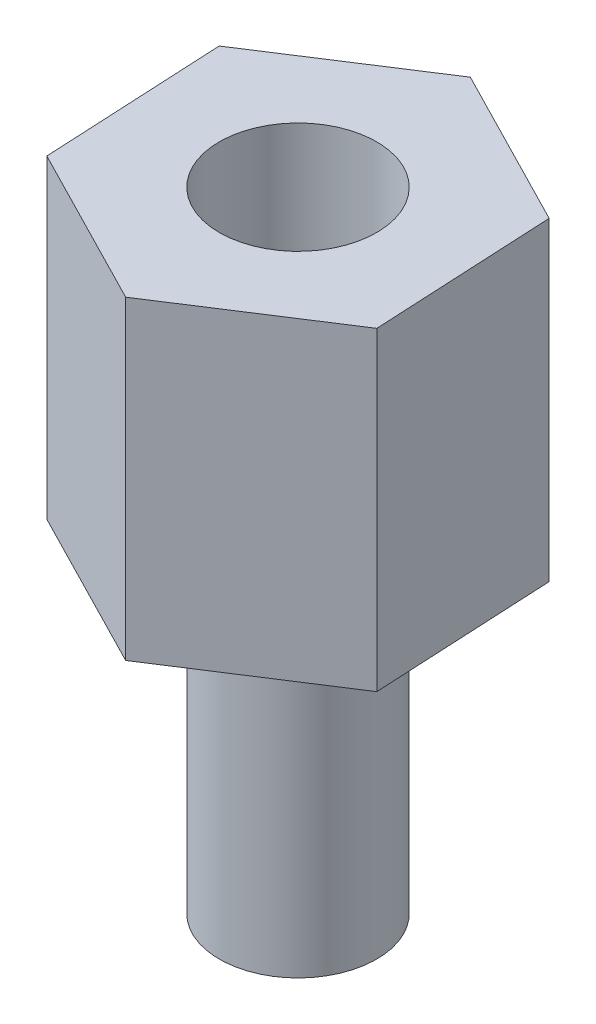
from build123d import *

# Parameters (mm, degrees)
EXTRUSION1_DEPTH        = 5
ESQUISSE2_R             = 1.25
EXTRUSION2_DEPTH        = 5
ESQUISSE3_R             = 1.25
ENL_V_MAT_EXTRU_2_DEPTH = 4


with BuildPart() as part:
    # Esquisse1 → Extrusion1 (new body)
    with BuildSketch(Plane(origin=(0, 0, 0), x_dir=(1, 0, 0), z_dir=(0, 1, 0))):
        Polygon((2.424630573, 1.56668437), (-0.144473178, 2.883133856), (-2.569103751, 1.316449486), (-2.424630573, -1.56668437), (0.144473178, -2.883133856), (2.569103751, -1.316449486), align=None)
    extrude(amount=EXTRUSION1_DEPTH)

    # Esquisse2 → Extrusion2 (add)
    with BuildSketch(Plane.XZ):
        with Locations(Location((0, 0, 0), (0, 0, 270))):  # turned: the seam where the file's is
            Circle(ESQUISSE2_R)
    extrude(amount=EXTRUSION2_DEPTH)

    # Esquisse3 → Enlèv. mat.-Extru.2 (cut)
    with BuildSketch(Plane(origin=(0, 5, 0), x_dir=(-1, 0, 0), z_dir=(0, 1, 0))):
        with Locations(Location((0, 0, 0), (0, 0, 270))):  # turned: the seam where the file's is
            Circle(ESQUISSE3_R)
    extrude(amount=-ENL_V_MAT_EXTRU_2_DEPTH, mode=Mode.SUBTRACT)


solid = part.part
